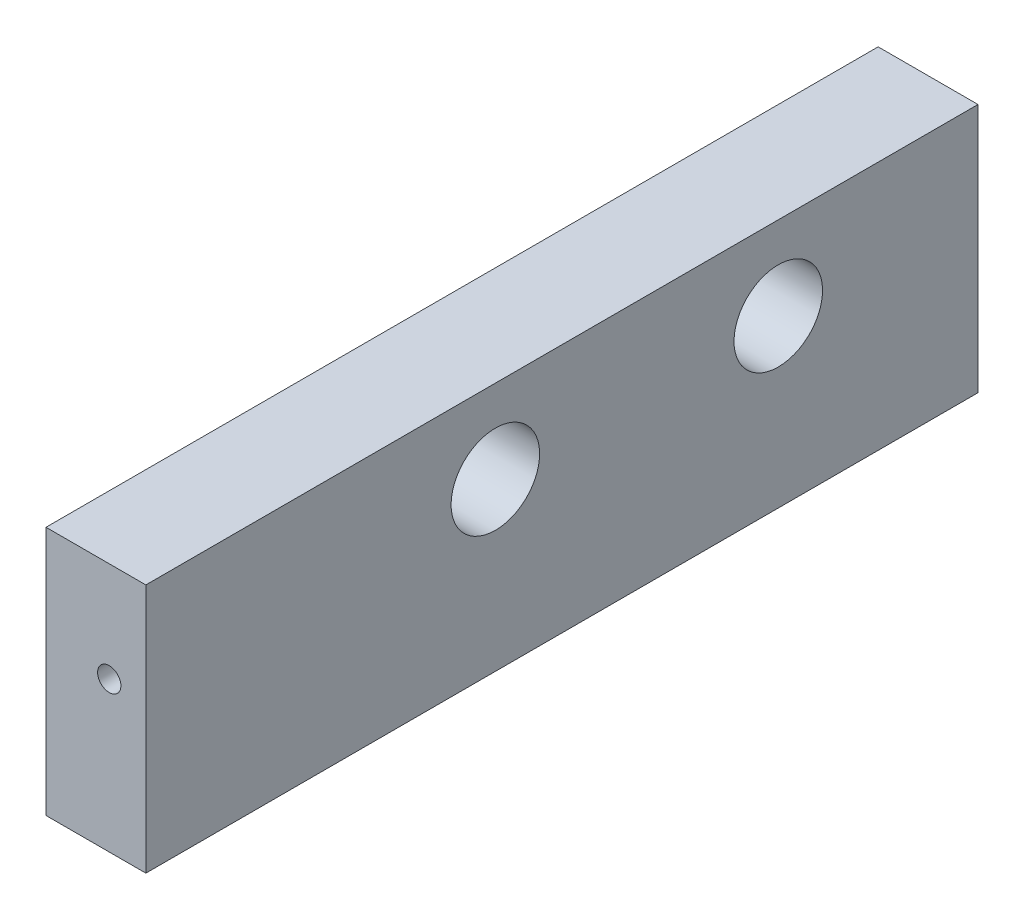
from build123d import *

# Parameters (mm, degrees)
SKETCH1_W           = 7.62
SKETCH1_H           = 19.05
BOSS_EXTRUDE1_DEPTH = 63.5
SKETCH2_R           = 0.889
CUT_EXTRUDE1_DEPTH  = 6.35
SKETCH3_R           = 3.3782
CUT_EXTRUDE2_DEPTH  = 8.62
SKETCH4_R           = 3.3782
CUT_EXTRUDE3_DEPTH  = 8.62


with BuildPart() as part:
    # Sketch1 → Boss-Extrude1 (new body)
    with BuildSketch(Plane.XY):
        with Locations((3.81, 9.525)):
            Rectangle(SKETCH1_W, SKETCH1_H)
    extrude(amount=-BOSS_EXTRUDE1_DEPTH)

    # Sketch2 → Cut-Extrude1 (cut)
    with BuildSketch(Plane.XY):
        with Locations((4.826, 11.43)):
            Circle(SKETCH2_R)
    extrude(amount=-CUT_EXTRUDE1_DEPTH, mode=Mode.SUBTRACT)

    # Sketch3 → Cut-Extrude2 (cut, through all)
    with BuildSketch(Plane.ZY):
        with Locations((-48.26, 12.7)):
            Circle(SKETCH3_R)
    extrude(amount=-CUT_EXTRUDE2_DEPTH, mode=Mode.SUBTRACT)

    # Sketch4 → Cut-Extrude3 (cut, through all)
    with BuildSketch(Plane.ZY):
        with Locations((-26.67, 12.7)):
            Circle(SKETCH4_R)
    extrude(amount=-CUT_EXTRUDE3_DEPTH, mode=Mode.SUBTRACT)


solid = part.part
